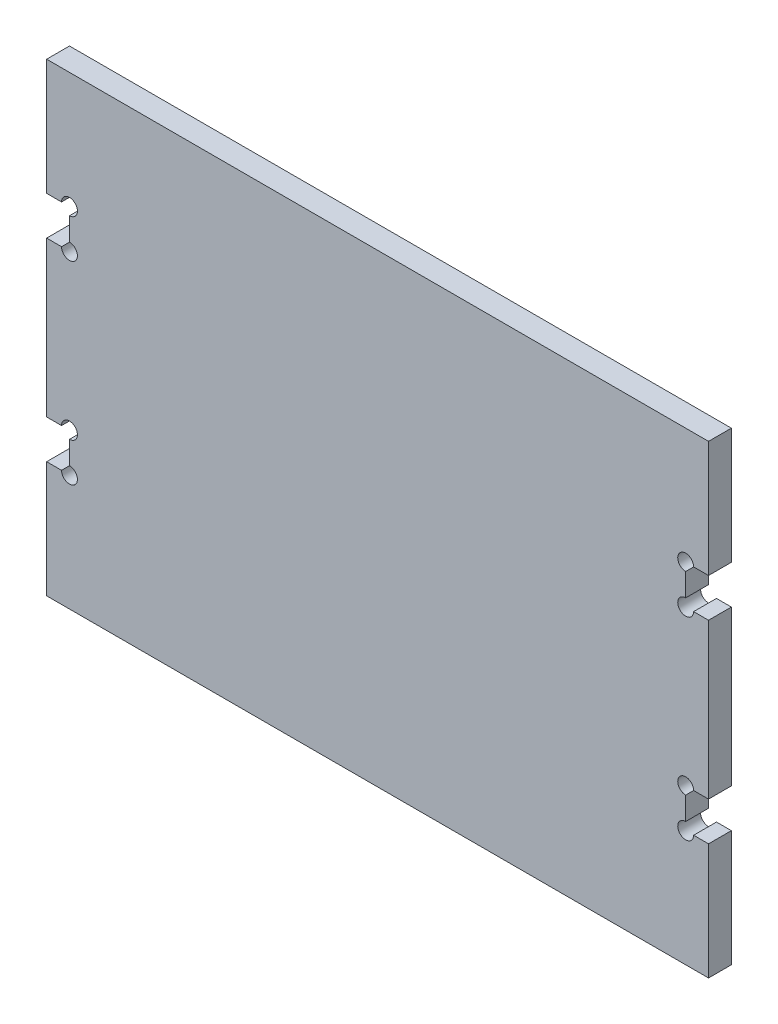
from build123d import *

# Parameters (mm, degrees)
SKETCH1_W           = 170.9
SKETCH1_H           = 120
BOSS_EXTRUDE1_DEPTH = 5.9
SKETCH2_W           = 5.9
SKETCH2_H           = 10
CUT_EXTRUDE1_DEPTH  = 6.9
CUT_EXTRUDE4_REACH  = 7.9
SKETCH5_R           = 2.05


with BuildPart() as part:
    # Sketch1 → Boss-Extrude1 (new body)
    with BuildSketch(Plane.XY):
        Rectangle(SKETCH1_W, SKETCH1_H)
    extrude(amount=BOSS_EXTRUDE1_DEPTH)

    # Sketch2 → Cut-Extrude1 (cut, through all)
    with BuildSketch(Plane.XY.offset(5.9)):
        with Locations((82.5, 25)):
            Rectangle(SKETCH2_W, SKETCH2_H)
        with Locations((82.5, -25)):
            Rectangle(SKETCH2_W, SKETCH2_H)
        with Locations((-82.5, -25)):
            Rectangle(SKETCH2_W, SKETCH2_H)
        with Locations((-82.5, 25)):
            Rectangle(SKETCH2_W, SKETCH2_H)
    extrude(amount=-CUT_EXTRUDE1_DEPTH, mode=Mode.SUBTRACT)

    # Sketch5 → Cut-Extrude4 (cut, up to next)
    with BuildSketch(Plane.XY.offset(5.9), mode=Mode.PRIVATE) as cut_extrude4_sk1:
        with Locations((-79.55, 30)):
            Circle(SKETCH5_R)
    cut_extrude4_tool1 = extrude(cut_extrude4_sk1.sketch, amount=-CUT_EXTRUDE4_REACH, mode=Mode.PRIVATE) & part.part
    add(cut_extrude4_tool1.solids().sort_by_distance((-79.55, 30, 5.9))[0], mode=Mode.SUBTRACT)
    # Sketch5 → Cut-Extrude4 (cut, up to next)
    with BuildSketch(Plane.XY.offset(5.9), mode=Mode.PRIVATE) as cut_extrude4_sk2:
        with Locations((-79.55, 20)):
            Circle(SKETCH5_R)
    cut_extrude4_tool2 = extrude(cut_extrude4_sk2.sketch, amount=-CUT_EXTRUDE4_REACH, mode=Mode.PRIVATE) & part.part
    add(cut_extrude4_tool2.solids().sort_by_distance((-79.55, 20, 5.9))[0], mode=Mode.SUBTRACT)
    # Sketch5 → Cut-Extrude4 (cut, up to next)
    with BuildSketch(Plane.XY.offset(5.9), mode=Mode.PRIVATE) as cut_extrude4_sk3:
        with Locations((-79.55, -20)):
            Circle(SKETCH5_R)
    cut_extrude4_tool3 = extrude(cut_extrude4_sk3.sketch, amount=-CUT_EXTRUDE4_REACH, mode=Mode.PRIVATE) & part.part
    add(cut_extrude4_tool3.solids().sort_by_distance((-79.55, -20, 5.9))[0], mode=Mode.SUBTRACT)
    # Sketch5 → Cut-Extrude4 (cut, up to next)
    with BuildSketch(Plane.XY.offset(5.9), mode=Mode.PRIVATE) as cut_extrude4_sk4:
        with Locations((-79.55, -30)):
            Circle(SKETCH5_R)
    cut_extrude4_tool4 = extrude(cut_extrude4_sk4.sketch, amount=-CUT_EXTRUDE4_REACH, mode=Mode.PRIVATE) & part.part
    add(cut_extrude4_tool4.solids().sort_by_distance((-79.55, -30, 5.9))[0], mode=Mode.SUBTRACT)
    # Sketch5 → Cut-Extrude4 (cut, up to next)
    with BuildSketch(Plane.XY.offset(5.9), mode=Mode.PRIVATE) as cut_extrude4_sk5:
        with Locations((79.55, -20)):
            Circle(SKETCH5_R)
    cut_extrude4_tool5 = extrude(cut_extrude4_sk5.sketch, amount=-CUT_EXTRUDE4_REACH, mode=Mode.PRIVATE) & part.part
    add(cut_extrude4_tool5.solids().sort_by_distance((79.55, -20, 5.9))[0], mode=Mode.SUBTRACT)
    # Sketch5 → Cut-Extrude4 (cut, up to next)
    with BuildSketch(Plane.XY.offset(5.9), mode=Mode.PRIVATE) as cut_extrude4_sk6:
        with Locations((79.55, -30)):
            Circle(SKETCH5_R)
    cut_extrude4_tool6 = extrude(cut_extrude4_sk6.sketch, amount=-CUT_EXTRUDE4_REACH, mode=Mode.PRIVATE) & part.part
    add(cut_extrude4_tool6.solids().sort_by_distance((79.55, -30, 5.9))[0], mode=Mode.SUBTRACT)
    # Sketch5 → Cut-Extrude4 (cut, up to next)
    with BuildSketch(Plane.XY.offset(5.9), mode=Mode.PRIVATE) as cut_extrude4_sk7:
        with Locations((79.55, 20)):
            Circle(SKETCH5_R)
    cut_extrude4_tool7 = extrude(cut_extrude4_sk7.sketch, amount=-CUT_EXTRUDE4_REACH, mode=Mode.PRIVATE) & part.part
    add(cut_extrude4_tool7.solids().sort_by_distance((79.55, 20, 5.9))[0], mode=Mode.SUBTRACT)
    # Sketch5 → Cut-Extrude4 (cut, up to next)
    with BuildSketch(Plane.XY.offset(5.9), mode=Mode.PRIVATE) as cut_extrude4_sk8:
        with Locations((79.55, 30)):
            Circle(SKETCH5_R)
    cut_extrude4_tool8 = extrude(cut_extrude4_sk8.sketch, amount=-CUT_EXTRUDE4_REACH, mode=Mode.PRIVATE) & part.part
    add(cut_extrude4_tool8.solids().sort_by_distance((79.55, 30, 5.9))[0], mode=Mode.SUBTRACT)


solid = part.part
